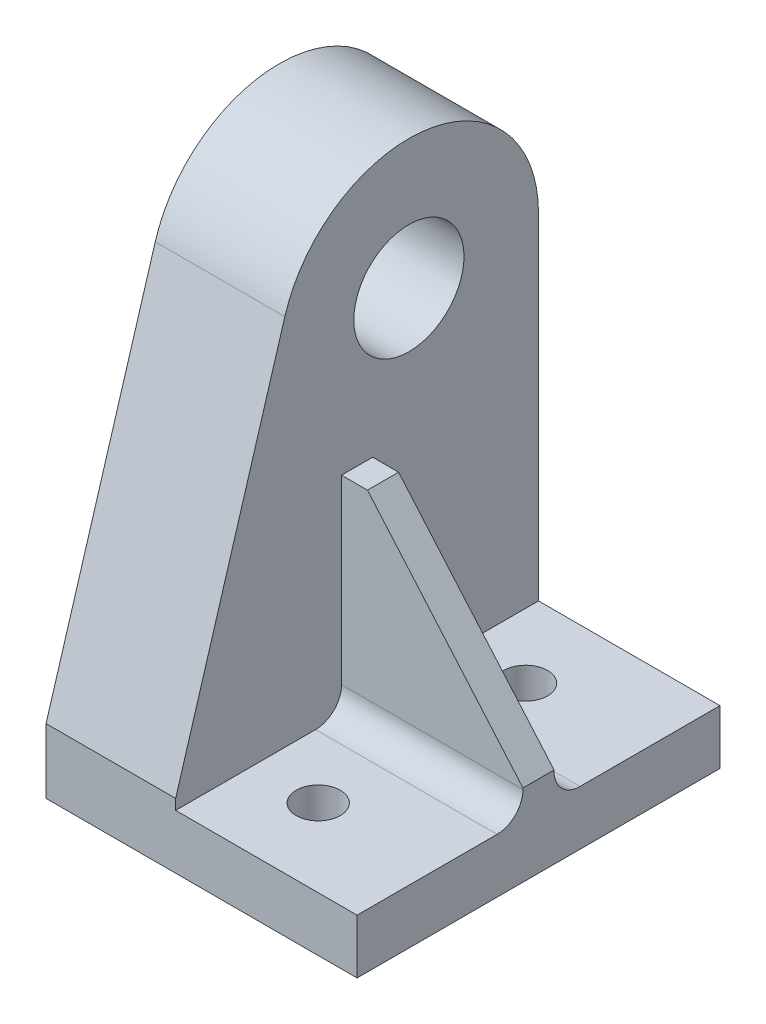
from build123d import *

# Parameters (mm, degrees)
SALIENTE_EXTRUIR1_DEPTH = 28
CROQUIS2_R              = 4.25
CORTAR_EXTRUIR1_DEPTH   = 25
CORTAR_EXTRUIR2_REACH   = 42.1
CROQUIS3_R              = 1.7
SALIENTE_EXTRUIR2_DEPTH = 1.2
REDONDEO1_R             = 2


with BuildPart() as part:
    # Croquis1 → Saliente-Extruir1 (new body)
    with BuildSketch(Plane.XY):
        Polygon((0, 4.2), (-14, 4.2), (-14, 40.1), (-24, 40.1), (-24, 0), (0, 0), align=None)
    extrude(amount=SALIENTE_EXTRUIR1_DEPTH)

    # Croquis2 → Cortar-Extruir1 (cut, through all)
    with BuildSketch(Plane.ZY.offset(24)):
        with Locations((10, 30.1)):
            Circle(CROQUIS2_R)
        with BuildLine():
            Line((28, 5), (19.575461286, 32.982800922))
            ThreePointArc((19.575461286, 32.982800922), (8.54305334, 39.993296035), (0, 30.1))
            Line((0, 30.1), (0, 29.1))
            Line((0, 29.1), (-1, 29.1))
            Line((-1, 29.1), (-1, 41.1))
            Line((-1, 41.1), (29, 41.1))
            Line((29, 41.1), (29, 5))
            Line((29, 5), (28, 5))
        make_face()
    extrude(amount=-CORTAR_EXTRUIR1_DEPTH, mode=Mode.SUBTRACT)

    # Croquis3 → Cortar-Extruir2 (cut, up to next)
    with BuildSketch(Plane.XZ, mode=Mode.PRIVATE) as cortar_extruir2_sk1:
        with Locations((-9, 22)):
            Circle(CROQUIS3_R)
    cortar_extruir2_tool1 = extrude(cortar_extruir2_sk1.sketch, amount=-CORTAR_EXTRUIR2_REACH, mode=Mode.PRIVATE) & part.part
    add(cortar_extruir2_tool1.solids().sort_by_distance((-9, 0, 22))[0], mode=Mode.SUBTRACT)
    # Croquis3 → Cortar-Extruir2 (cut, up to next)
    with BuildSketch(Plane.XZ, mode=Mode.PRIVATE) as cortar_extruir2_sk2:
        with Locations((-9, 6)):
            Circle(CROQUIS3_R)
    cortar_extruir2_tool2 = extrude(cortar_extruir2_sk2.sketch, amount=-CORTAR_EXTRUIR2_REACH, mode=Mode.PRIVATE) & part.part
    add(cortar_extruir2_tool2.solids().sort_by_distance((-9, 0, 6))[0], mode=Mode.SUBTRACT)

    # Croquis4 → Saliente-Extruir2 (add, symmetric)
    with BuildSketch(Plane(origin=(0, 0, 14), x_dir=(-1, 0, 0), z_dir=(0, 0, -1))):
        Polygon((0, 4.2), (14, 4.2), (14, 20.2), (12, 20.2), (0, 6.3), align=None)
    extrude(amount=SALIENTE_EXTRUIR2_DEPTH, both=True)

    # Redondeo1
    redondeo1_edges = [part.edges().sort_by_distance(p)[0] for p in [
        (-7, 4.2, 15.2),
        (-7, 4.2, 12.8),
    ]]
    fillet(redondeo1_edges, radius=REDONDEO1_R)


solid = part.part
